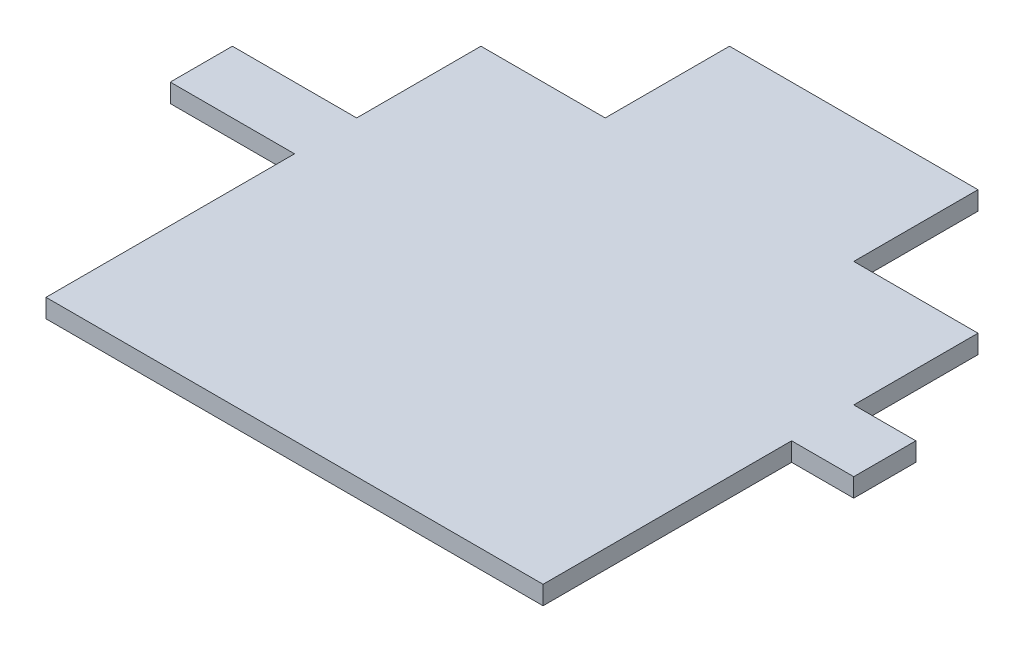
from build123d import *

# Parameters (mm, degrees)
EXTRUDE_1_DEPTH = 3


with BuildPart() as part:
    # 草图1 → 凸台-拉伸1 (new body)
    with BuildSketch(Plane(origin=(0, 0, 0), x_dir=(1, 0, 0), z_dir=(0, 1, 0))):
        Polygon((-38.565044459, -42.794760037), (-38.565044459, -82.794760037), (41.434955541, -82.794760037), (41.434955541, -42.794760037), (51.434955541, -42.794760037), (51.434955541, -32.794760037), (41.434955541, -32.794760037), (41.434955541, -12.794760037), (21.434955541, -12.794760037), (21.434955541, 7.205239963), (-18.565044459, 7.205239963), (-18.565044459, -12.794760037), (-38.565044459, -12.794760037), (-38.565044459, -32.794760037), (-58.565044459, -32.794760037), (-58.565044459, -42.794760037), align=None)
    extrude(amount=EXTRUDE_1_DEPTH)


solid = part.part
